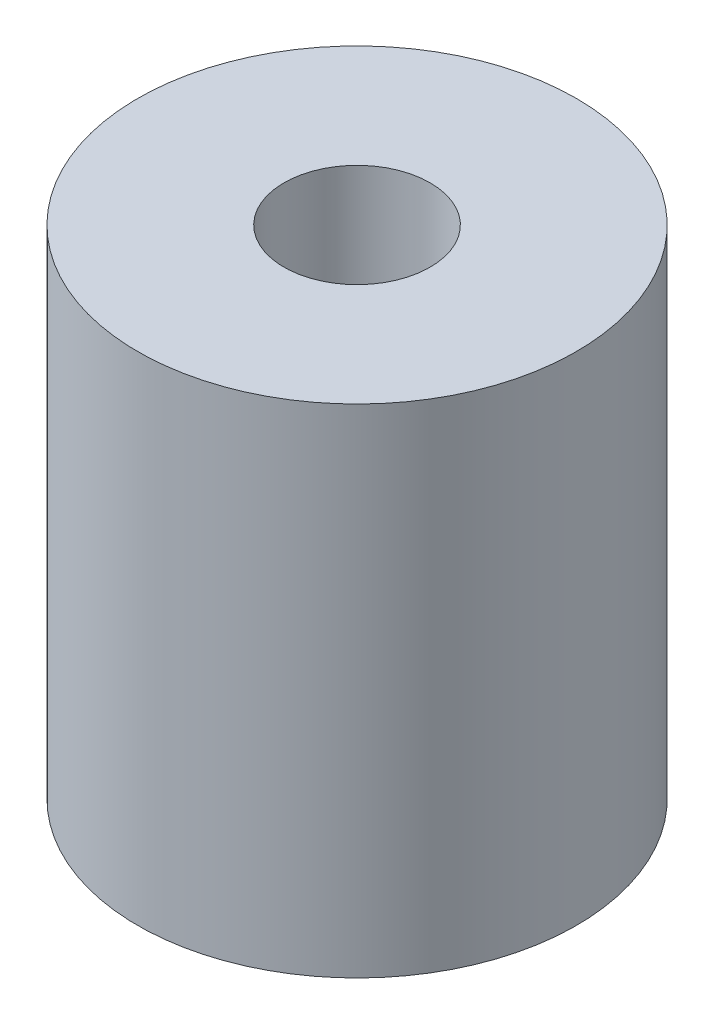
from build123d import *

# Parameters (mm, degrees)
SKETCH1_W = 6.35
SKETCH1_H = 21.59


with BuildPart() as part:
    # Sketch1 → Revolve1 (revolve)
    with BuildSketch(Plane.XY):
        with Locations((6.35, 10.795)):
            Rectangle(SKETCH1_W, SKETCH1_H)
    revolve(axis=Axis((0, 21.59, 0), (0, -1, 0)))


solid = part.part
